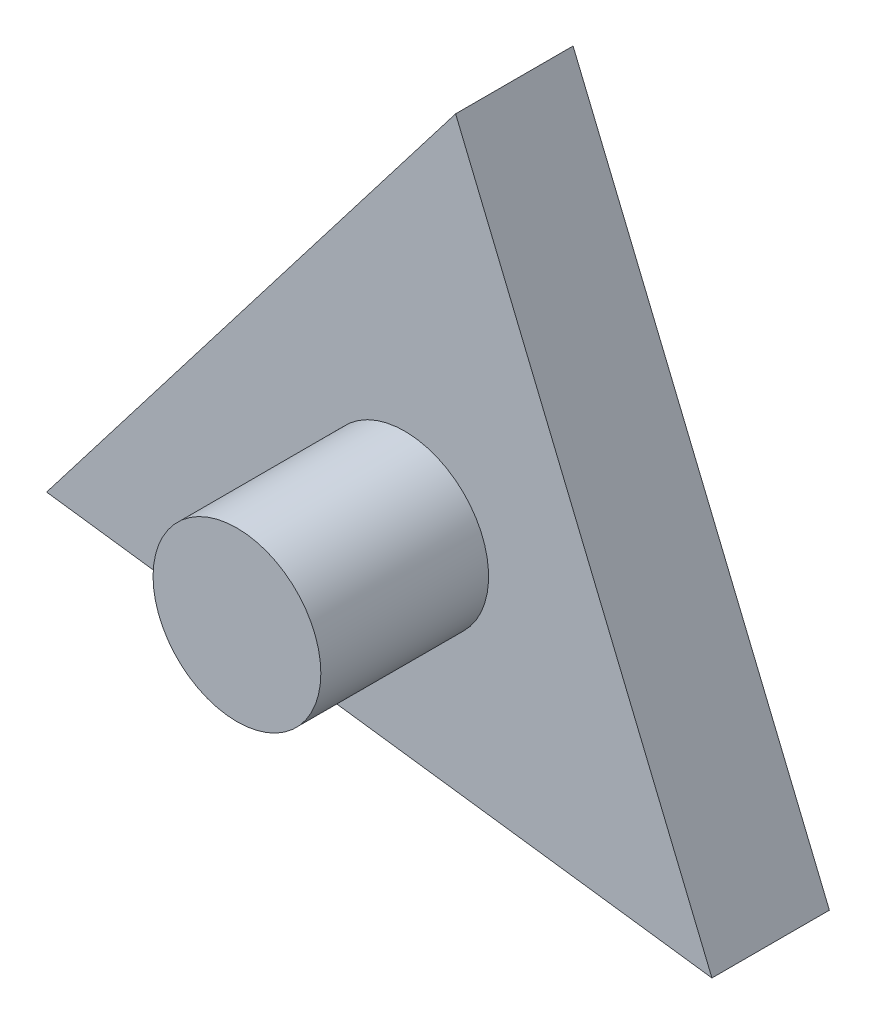
from build123d import *

# Parameters (mm, degrees)
BOSS_EXTRU_1_DEPTH = 7
ESQUISSE2_R        = 5
BOSS_EXTRU_2_DEPTH = 10


with BuildPart() as part:
    # Esquisse1 → Boss.-Extru.1 (new body)
    with BuildSketch(Plane.XY):
        Polygon((-21.343464827, -8.819855018), (3.03351391, 22.893910253), (18.309950916, -14.074055236), align=None)
    extrude(amount=BOSS_EXTRU_1_DEPTH)

    # Esquisse2 → Boss.-Extru.2 (add)
    with BuildSketch(Plane.XY.offset(7)):
        Circle(ESQUISSE2_R)
    extrude(amount=BOSS_EXTRU_2_DEPTH)


solid = part.part
